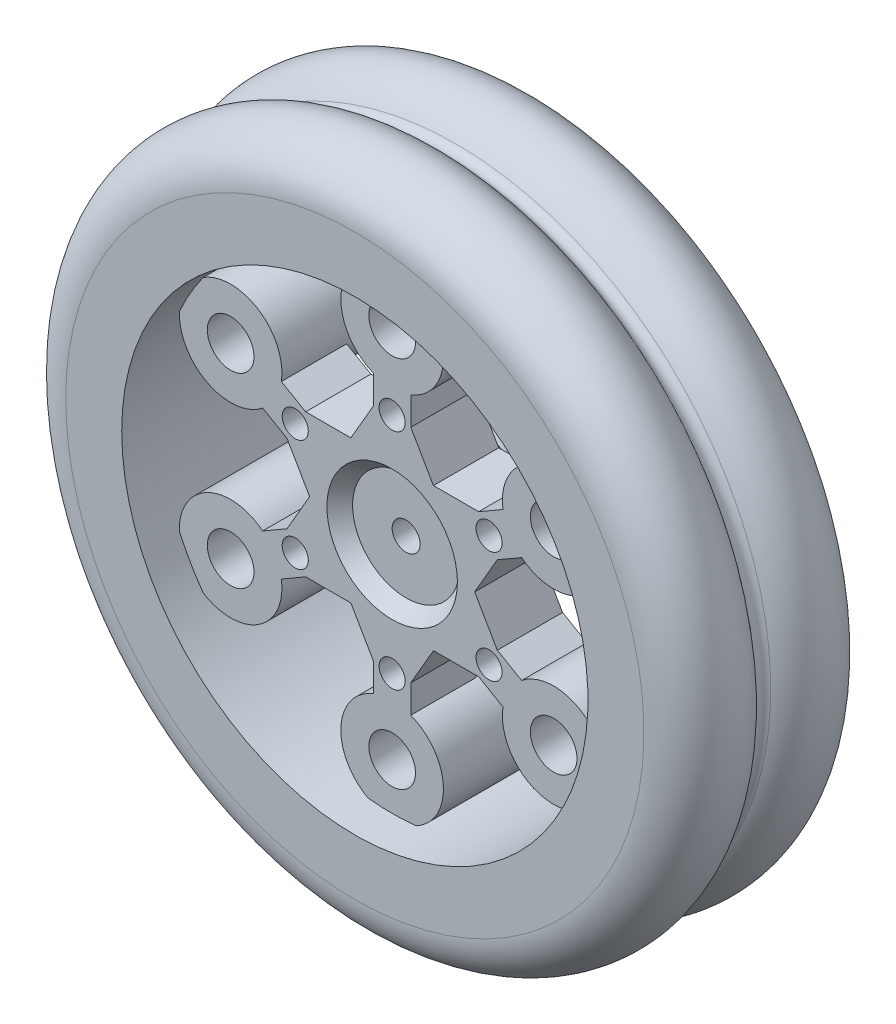
from build123d import *

# Parameters (mm, degrees)
SKETCH_2_R               = 5.5
EXTRUDE_1_DEPTH          = 10
PATTERN_CIRCULAR_1_COUNT = 6
EXTRUDE_2_DEPTH          = 7
SKETCH_4_R               = 1.4
CUT_EXTRUDE_1_DEPTH      = 12
PATTERN_CIRCULAR_2_COUNT = 6
SKETCH_5_R               = 9
EXTRUDE_3_DEPTH          = 5
SKETCH_7_R               = 7
CUT_EXTRUDE_3_DEPTH      = 1.5
CUT_EXTRUDE_3_TAPER      = 40
SKETCH_8_R               = 1.5
CUT_EXTRUDE_4_DEPTH      = 15.5
SKETCH_10_R              = 1.25
CUT_EXTRUDE_6_DEPTH      = 17
SKETCH_11_R              = 2.5
CUT_EXTRUDE_7_DEPTH      = 17
PATTERN_CIRCULAR_4_COUNT = 6
CUT_EXTRUDE_9_DEPTH      = 8


with BuildPart() as part:
    # 草图1 → 旋转1 (revolve)
    with BuildSketch(Plane(origin=(0, 0, 0), x_dir=(1, 0, 0), z_dir=(0, 1, 0))):
        with BuildLine():
            Line((25, 10), (25, -10))
            Line((25, -10), (31, -10))
            ThreePointArc((31, -10), (35.787135539, -6.443375673), (33.763853992, -0.833333333))
            ThreePointArc((33.763853992, -0.833333333), (33.31662479, 0), (33.763853992, 0.833333333))
            ThreePointArc((33.763853992, 0.833333333), (35.787135539, 6.443375673), (31, 10))
            Line((31, 10), (25, 10))
        make_face()
    revolve(axis=Axis((0, 0, -146.934042126), (0, 0, 1)))

    # 草图2 → 凸台-拉伸1 (add)
    with BuildSketch(Plane.XY.offset(6)):
        with Locations((0, 20)):
            Circle(SKETCH_2_R)
    extrude_1 = extrude(amount=-EXTRUDE_1_DEPTH)

    # 阵列(圆周)1: 凸台-拉伸1 ×6 about axis
    pattern_circular_1_axis = Axis((0, 0, 0), (0, 0, 1))
    for i in range(1, PATTERN_CIRCULAR_1_COUNT):
        add(extrude_1.rotate(pattern_circular_1_axis, i * 360 / PATTERN_CIRCULAR_1_COUNT))

    # 草图3 → 凸台-拉伸2 (add)
    with BuildSketch(Plane.XY.offset(6)):
        with BuildLine():
            Line((-8.849844437, 0), (-11.274766656, -4.200088487))
            Line((-11.274766656, -4.200088487), (-13.883448238, -5.706211501))
            ThreePointArc((-13.883448238, -5.706211501), (-12.557368355, -7.25), (-11.883448238, -9.170313116))
            Line((-11.883448238, -9.170313116), (-9.274766656, -7.664190102))
            Line((-9.274766656, -7.664190102), (-4.424922219, -7.664190102))
            Line((-4.424922219, -7.664190102), (-2, -11.864278589))
            Line((-2, -11.864278589), (-2, -14.876524617))
            ThreePointArc((-2, -14.876524617), (0, -14.5), (2, -14.876524617))
            Line((2, -14.876524617), (2, -11.864278589))
            Line((2, -11.864278589), (4.424922219, -7.664190102))
            Line((4.424922219, -7.664190102), (9.274766656, -7.664190102))
            Line((9.274766656, -7.664190102), (11.883448238, -9.170313116))
            ThreePointArc((11.883448238, -9.170313116), (12.557368355, -7.25), (13.883448238, -5.706211501))
            Line((13.883448238, -5.706211501), (11.274766656, -4.200088487))
            Line((11.274766656, -4.200088487), (8.849844437, 0))
            Line((8.849844437, 0), (11.274766656, 4.200088487))
            Line((11.274766656, 4.200088487), (13.883448238, 5.706211501))
            ThreePointArc((13.883448238, 5.706211501), (12.557368355, 7.25), (11.883448238, 9.170313116))
            Line((11.883448238, 9.170313116), (9.274766656, 7.664190102))
            Line((9.274766656, 7.664190102), (4.424922219, 7.664190102))
            Line((4.424922219, 7.664190102), (2, 11.864278589))
            Line((2, 11.864278589), (2, 14.876524617))
            ThreePointArc((2, 14.876524617), (0, 14.5), (-2, 14.876524617))
            Line((-2, 14.876524617), (-2, 11.864278589))
            Line((-2, 11.864278589), (-4.424922219, 7.664190102))
            Line((-4.424922219, 7.664190102), (-9.274766656, 7.664190102))
            Line((-9.274766656, 7.664190102), (-11.883448238, 9.170313116))
            ThreePointArc((-11.883448238, 9.170313116), (-12.557368355, 7.25), (-13.883448238, 5.706211501))
            Line((-13.883448238, 5.706211501), (-11.274766656, 4.200088487))
            Line((-11.274766656, 4.200088487), (-8.849844437, 0))
        make_face()
    extrude(amount=-EXTRUDE_2_DEPTH)

    # 草图4 → 切除-拉伸1 (cut, through all)
    with BuildSketch(Plane(origin=(0, 0, -1), x_dir=(-1, 0, 0), z_dir=(0, 0, -1))):
        with Locations((0, 12)):
            Circle(SKETCH_4_R)
    cut_extrude_1 = extrude(amount=-CUT_EXTRUDE_1_DEPTH, mode=Mode.SUBTRACT)

    # 阵列(圆周)2: 切除-拉伸1 ×6 about axis
    pattern_circular_2_axis = Axis((0, 0, 0), (0, 0, 1))
    for i in range(1, PATTERN_CIRCULAR_2_COUNT):
        add(cut_extrude_1.rotate(pattern_circular_2_axis, i * 360 / PATTERN_CIRCULAR_2_COUNT), mode=Mode.SUBTRACT)

    # 草图5 → 凸台-拉伸3 (add)
    with BuildSketch(Plane(origin=(0, 0, -1), x_dir=(-1, 0, 0), z_dir=(0, 0, -1))):
        Circle(SKETCH_5_R)
    extrude(amount=EXTRUDE_3_DEPTH)

    # 草图7 → 切除-拉伸3 (cut)
    with BuildSketch(Plane.XY.offset(6)):
        Circle(SKETCH_7_R)
    extrude(amount=-CUT_EXTRUDE_3_DEPTH, taper=CUT_EXTRUDE_3_TAPER, mode=Mode.SUBTRACT)

    # 草图8 → 切除-拉伸4 (cut, through all)
    with BuildSketch(Plane.XY.offset(4.5)):
        Circle(SKETCH_8_R)
    extrude(amount=-CUT_EXTRUDE_4_DEPTH, mode=Mode.SUBTRACT)

    # 草图10 → 切除-拉伸6 (cut, through all)
    with BuildSketch(Plane.XY.offset(6)):
        with Locations((0, 20)):
            Circle(SKETCH_10_R)
    extrude(amount=-CUT_EXTRUDE_6_DEPTH, mode=Mode.SUBTRACT)

    # 草图11 → 切除-拉伸7 (cut, through all)
    with BuildSketch(Plane.XY.offset(6)):
        with Locations((0, 20)):
            Circle(SKETCH_11_R)
    cut_extrude_7 = extrude(amount=-CUT_EXTRUDE_7_DEPTH, mode=Mode.SUBTRACT)

    # 阵列(圆周)4: 切除-拉伸7 ×6 about axis
    pattern_circular_4_axis = Axis((0, 0, 0), (0, 0, 1))
    for i in range(1, PATTERN_CIRCULAR_4_COUNT):
        add(cut_extrude_7.rotate(pattern_circular_4_axis, i * 360 / PATTERN_CIRCULAR_4_COUNT), mode=Mode.SUBTRACT)

    # 草图14 → 切除-拉伸9 (cut)
    with BuildSketch(Plane(origin=(0, 0, -6), x_dir=(-1, 0, 0), z_dir=(0, 0, -1))):
        Polygon((0, 6.92820323), (-6, 3.464101615), (-6, -3.464101615), (0, -6.92820323), (6, -3.464101615), (6, 3.464101615), align=None)
    extrude(amount=-CUT_EXTRUDE_9_DEPTH, mode=Mode.SUBTRACT)


solid = part.part
